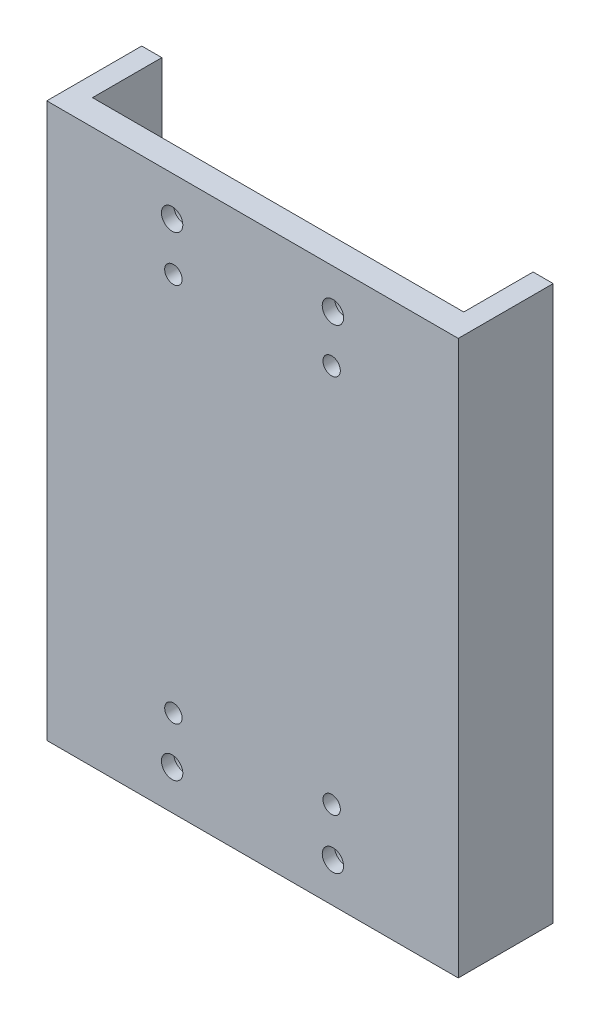
from build123d import *

# Parameters (mm, degrees)
BOSS_EXTRUDE1_DEPTH                                  = 87.5
CBORE_FOR_1_4_BINDING_HEAD_MACHINE_SCREW_D           = 6.7564
CBORE_FOR_1_4_BINDING_HEAD_MACHINE_SCREW_CBORE_D     = 14.2875
CBORE_FOR_1_4_BINDING_HEAD_MACHINE_SCREW_CBORE_DEPTH = 4.191
CBORE_FOR_M5_HEX_HEAD_BOLT1_D                        = 5.5
CBORE_FOR_M5_HEX_HEAD_BOLT1_CBORE_D                  = 12.24
CBORE_FOR_M5_HEX_HEAD_BOLT1_CBORE_DEPTH              = 3.58


with BuildPart() as part:
    # Sketch1 → Boss-Extrude1 (new body, symmetric)
    with BuildSketch(Plane(origin=(0, 0, 0), x_dir=(1, 0, 0), z_dir=(0, 1, 0))):
        Polygon((58.65, 30), (65, 30), (65, 0), (-65, 0), (-65, 30), (-58.65, 30), (-58.65, 8.0907173), (58.65, 8.0907173), align=None)
    extrude(amount=BOSS_EXTRUDE1_DEPTH, both=True)

    # CBORE for 1/4 Binding Head Machine Screw1 (through all)
    with Locations(Plane(origin=(0, 0, -8.0907173), x_dir=(-1, 0, 0), z_dir=(0, 0, -1))):
        with Locations((-25.4, 75), (25.4, -75), (-25.4, -75), (25.4, 75)):
            CounterBoreHole(CBORE_FOR_1_4_BINDING_HEAD_MACHINE_SCREW_D / 2, CBORE_FOR_1_4_BINDING_HEAD_MACHINE_SCREW_CBORE_D / 2, CBORE_FOR_1_4_BINDING_HEAD_MACHINE_SCREW_CBORE_DEPTH)

    # CBORE for M5 Hex Head Bolt1 (through all)
    with Locations(Plane(origin=(0, 0, -8.0907173), x_dir=(-1, 0, 0), z_dir=(0, 0, -1))):
        with Locations((25, -60), (-25, 60), (-25, -60), (25, 60)):
            CounterBoreHole(CBORE_FOR_M5_HEX_HEAD_BOLT1_D / 2, CBORE_FOR_M5_HEX_HEAD_BOLT1_CBORE_D / 2, CBORE_FOR_M5_HEX_HEAD_BOLT1_CBORE_DEPTH)


solid = part.part
